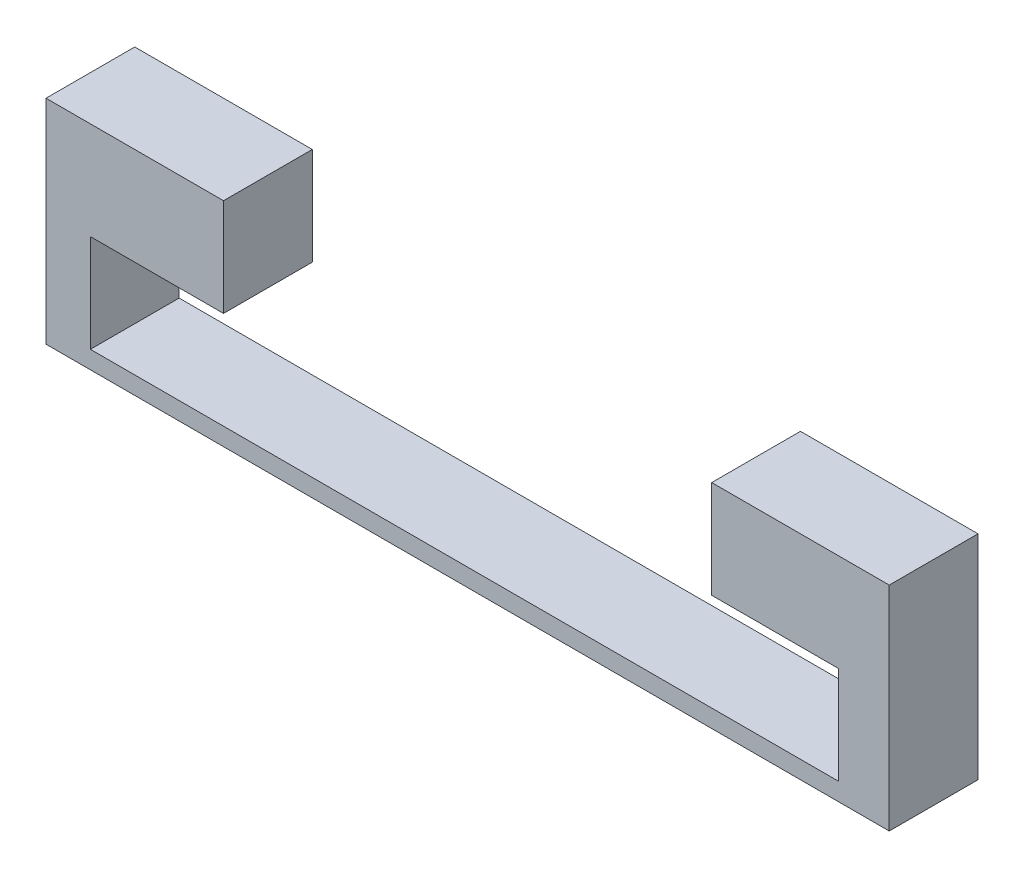
from build123d import *

# Parameters (mm, degrees)
BOSS_EXTRUDE1_DEPTH = 2


with BuildPart() as part:
    # Sketch1 → Boss-Extrude1 (new body)
    with BuildSketch(Plane.XY):
        Polygon((0, 0), (19, 0), (19, 4.8), (15, 4.8), (15, 2.6), (17.855643045, 2.6), (17.855643045, 0.4), (1, 0.4), (1, 2.6), (4, 2.6), (4, 4.8), (0, 4.8), align=None)
    extrude(amount=BOSS_EXTRUDE1_DEPTH)


solid = part.part
